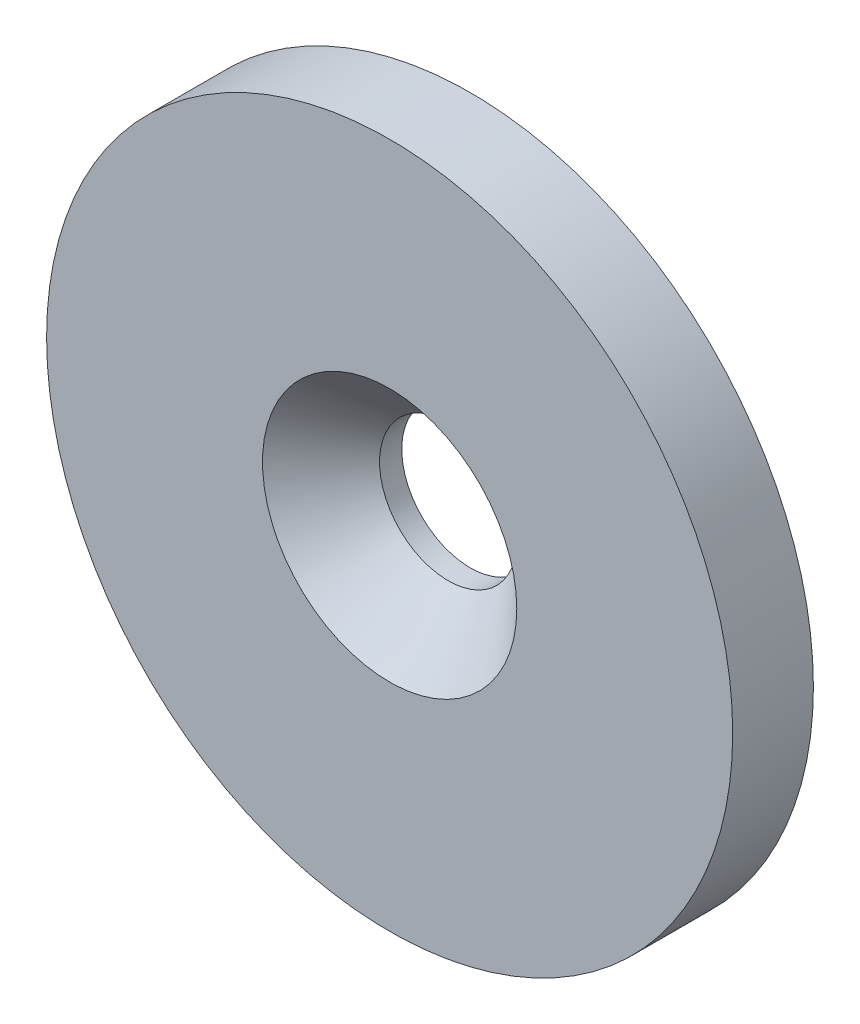
from build123d import *

# Parameters (mm, degrees)
SKETCH1_R           = 8.5
BOSS_EXTRUDE1_DEPTH = 2


with BuildPart() as part:
    # Sketch1 → Boss-Extrude1 (new body)
    with BuildSketch(Plane.XY):
        Circle(SKETCH1_R)
    extrude(amount=-BOSS_EXTRUDE1_DEPTH)

    # Sketch3 → CSK for M3 Flat Head Machine Screw1 (revolve, cut)
    with BuildSketch(Plane(origin=(0, 0, 0), x_dir=(0, -1, 0), z_dir=(1, 0, 0))):
        Polygon((0, 0), (0, 2), (1.7, 2), (1.7, 1.45), (3.15, 0), align=None)
    revolve(axis=Axis((0, 0, 6.35), (0, 0, -1)), mode=Mode.SUBTRACT)


solid = part.part
